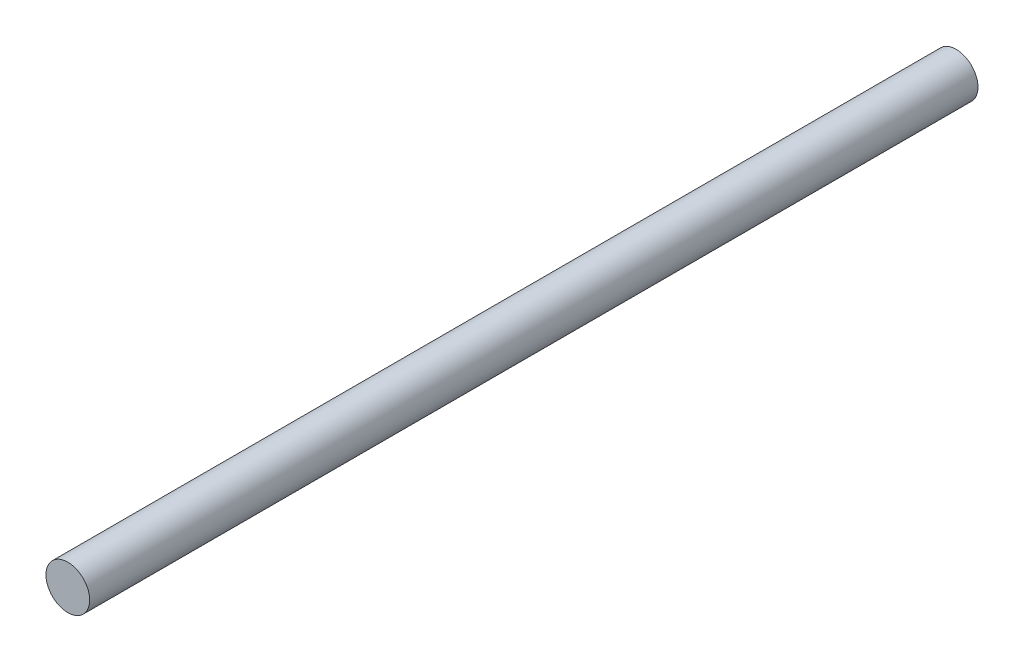
from build123d import *

# Parameters (mm, degrees)
ESQUISSE1_R = 1.6
MAIN_DEPTH  = 65


with BuildPart() as part:
    # Esquisse1 → Main (new body)
    with BuildSketch(Plane.XY):
        Circle(ESQUISSE1_R)
    extrude(amount=MAIN_DEPTH)


solid = part.part
